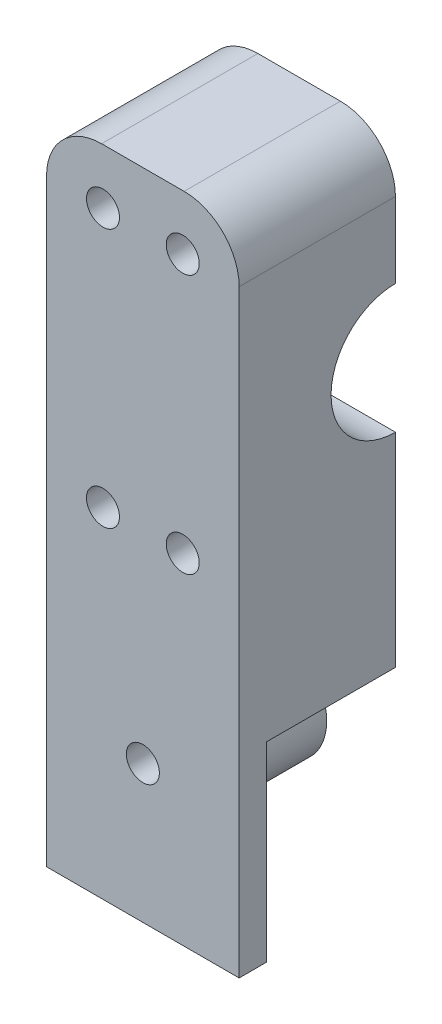
from build123d import *

# Parameters (mm, degrees)
SKETCH1_R               = 11.7
BOSS_EXTRUDE1_DEPTH     = 35
SKETCH2_R               = 10
BOSS_EXTRUDE3_DEPTH     = 51.8
SKETCH3_R               = 3
CUT_EXTRUDE1_DEPTH      = 1
CUT_EXTRUDE1_DEPTH_BACK = 57.8
SKETCH6_W               = 28.4
SKETCH6_H               = 118.8
CUT_EXTRUDE3_DEPTH      = 36
SKETCH8_R               = 10
SKETCH8_R_2             = 3
CUT_EXTRUDE4_DEPTH      = 5
SKETCH7_R               = 4
SKETCH7_R_2             = 3
CUT_EXTRUDE5_DEPTH      = 5
FILLET1_R               = 10


with BuildPart() as part:
    # Sketch1 → Boss-Extrude1 (new body)
    with BuildSketch(Plane(origin=(0, 0, 0), x_dir=(0, 0, -1), z_dir=(1, 0, 0))):
        Polygon((-28.4, -59.4), (-23.4, -59.4), (-23.4, -14.4), (23.4, -14.4), (23.4, -59.4), (28.4, -59.4), (28.4, 59.4), (-28.4, 59.4), align=None)
        with Locations((0, 24)):
            Circle(SKETCH1_R, mode=Mode.SUBTRACT)
    extrude(amount=BOSS_EXTRUDE1_DEPTH)

    # Sketch2 → Boss-Extrude3 (add)
    with BuildSketch(Plane.XY.offset(28.4)):
        with Locations((17.5, -34.4)):
            Circle(SKETCH2_R)
        with BuildLine():
            Line((0, -24.717541634), (0, -13.4))
            Line((0, -13.4), (35, -13.4))
            Line((35, -13.4), (35, -24.717541634))
            ThreePointArc((35, -24.717541634), (17.5, -14.4), (0, -24.717541634))
        make_face()
    extrude(amount=-BOSS_EXTRUDE3_DEPTH)

    # Sketch3 → Cut-Extrude1 (cut, two sides)
    with BuildSketch(Plane.XY.offset(28.4)) as cut_extrude1_sk:
        with Locations((10.25, 49.4)):
            Circle(SKETCH3_R)
        with Locations((17.5, -34.4)):
            Circle(SKETCH3_R)
        with Locations((10.25, 2.3)):
            Circle(SKETCH3_R)
        with Locations((24.75, 2.3)):
            Circle(SKETCH3_R)
        with Locations((24.75, 49.4)):
            Circle(SKETCH3_R)
    extrude(amount=CUT_EXTRUDE1_DEPTH, mode=Mode.SUBTRACT)
    extrude(cut_extrude1_sk.sketch, amount=-CUT_EXTRUDE1_DEPTH_BACK, mode=Mode.SUBTRACT)

    # Sketch6 → Cut-Extrude3 (cut, through all)
    with BuildSketch(Plane(origin=(35, 0, 0), x_dir=(0, 0, -1), z_dir=(1, 0, 0))):
        with Locations((14.2, 0)):
            Rectangle(SKETCH6_W, SKETCH6_H)
    extrude(amount=-CUT_EXTRUDE3_DEPTH, mode=Mode.SUBTRACT)

    # Sketch8 → Cut-Extrude4 (cut)
    with BuildSketch(Plane(origin=(0, 0, 0), x_dir=(-1, 0, 0), z_dir=(0, 0, -1))):
        with Locations((-17.5, -34.4)):
            Circle(SKETCH8_R)
        with Locations((-17.5, -34.4)):
            Circle(SKETCH8_R_2, mode=Mode.SUBTRACT)
    extrude(amount=-CUT_EXTRUDE4_DEPTH, mode=Mode.SUBTRACT)

    # Sketch7 → Cut-Extrude5 (cut)
    with BuildSketch(Plane(origin=(0, 0, 0), x_dir=(-1, 0, 0), z_dir=(0, 0, -1))):
        with Locations((-24.75, 49.4)):
            Circle(SKETCH7_R)
        with Locations((-24.75, 49.4)):
            Circle(SKETCH7_R_2, mode=Mode.SUBTRACT)
        with Locations((-10.25, 49.4)):
            Circle(SKETCH7_R)
        with Locations((-10.25, 49.4)):
            Circle(SKETCH7_R_2, mode=Mode.SUBTRACT)
        with Locations((-24.75, 2.3)):
            Circle(SKETCH7_R)
        with Locations((-24.75, 2.3)):
            Circle(SKETCH7_R_2, mode=Mode.SUBTRACT)
        with Locations((-10.25, 2.3)):
            Circle(SKETCH7_R)
        with Locations((-10.25, 2.3)):
            Circle(SKETCH7_R_2, mode=Mode.SUBTRACT)
    extrude(amount=-CUT_EXTRUDE5_DEPTH, mode=Mode.SUBTRACT)

    # Fillet1
    fillet1_edges = [part.edges().sort_by_distance(p)[0] for p in [
        (0, 59.4, 14.2),
        (35, 59.4, 14.2),
    ]]
    fillet(fillet1_edges, radius=FILLET1_R)


solid = part.part
